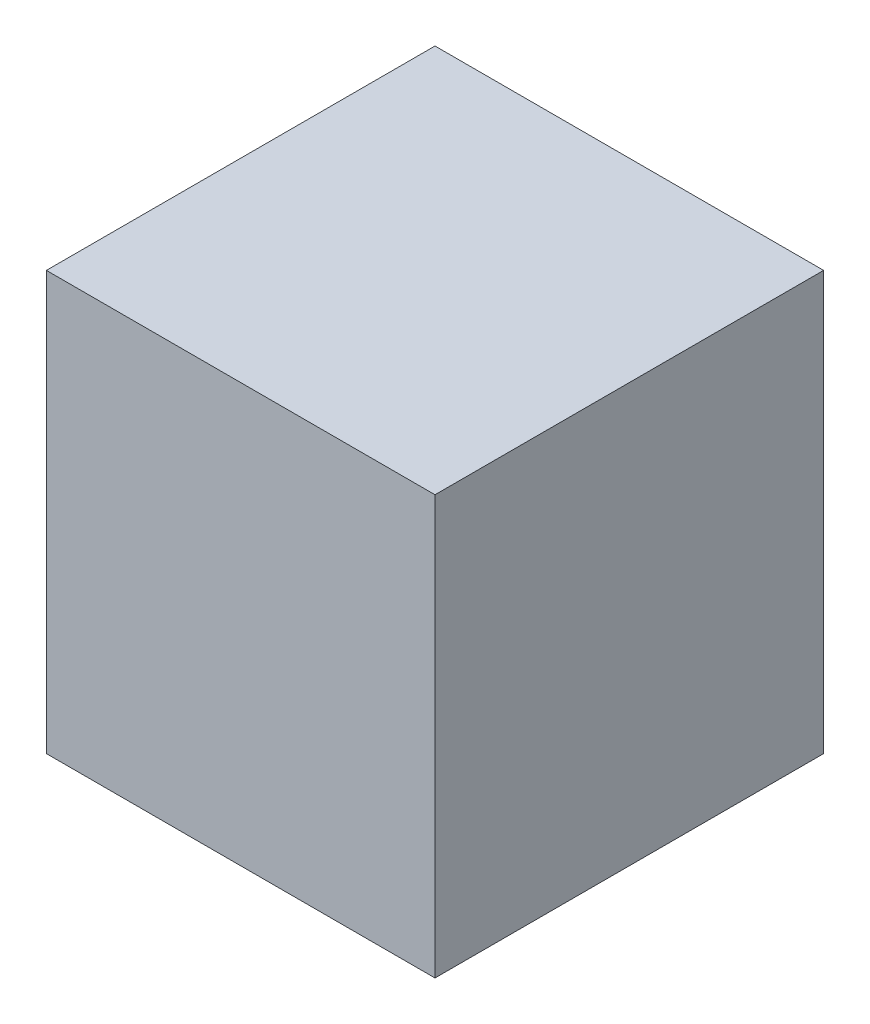
from build123d import *

# Parameters (mm, degrees)
SKETCH1_W           = 165.1
SKETCH1_H           = 165.1
BOSS_EXTRUDE1_DEPTH = 177.8


with BuildPart() as part:
    # Sketch1 → Boss-Extrude1 (new body)
    with BuildSketch(Plane(origin=(0, 0, 0), x_dir=(1, 0, 0), z_dir=(0, 1, 0))):
        with Locations((82.55, -82.55)):
            Rectangle(SKETCH1_W, SKETCH1_H)
    extrude(amount=BOSS_EXTRUDE1_DEPTH)


solid = part.part
